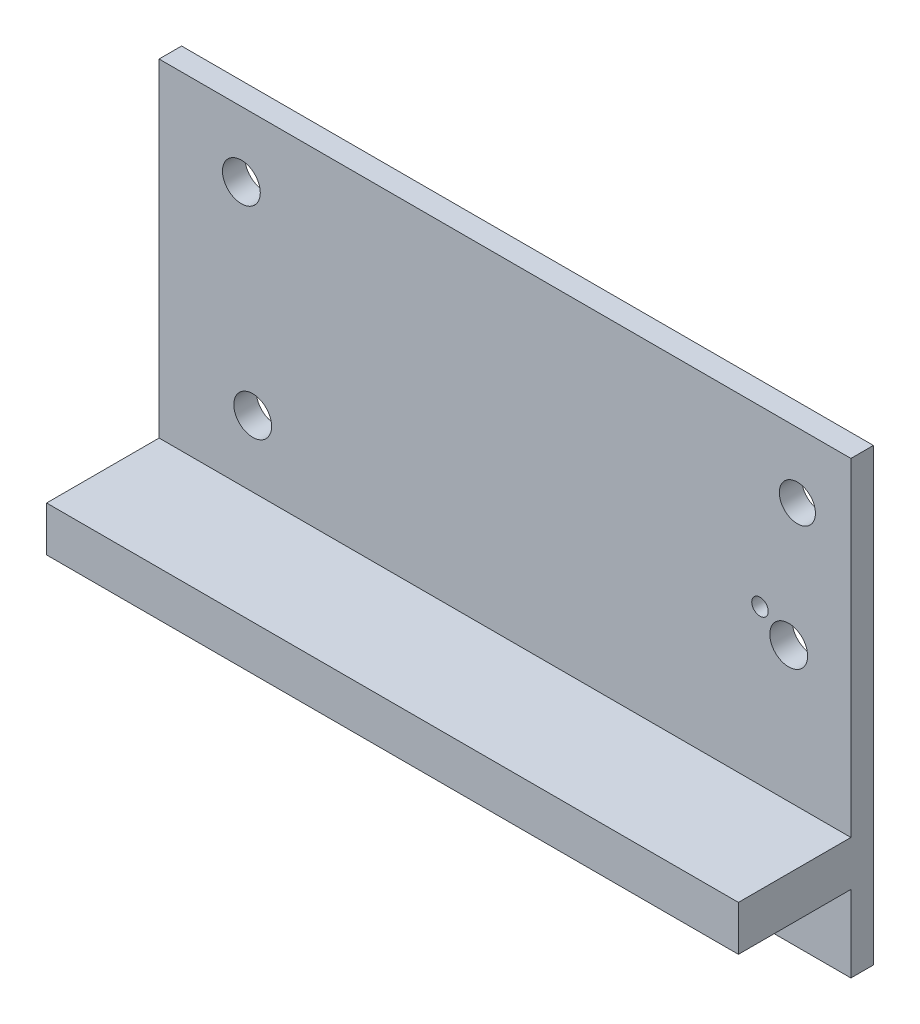
from build123d import *

# Parameters (mm, degrees)
ESQUISSE14_W       = 61.498402753
ESQUISSE14_H       = 40
ESQUISSE14_R       = 1.605618906
ESQUISSE14_R_2     = 1.680447067
ESQUISSE14_R_3     = 0.733091197
BOSS_EXTRU_1_DEPTH = 2
ESQUISSE15_W       = 61.498402753
ESQUISSE15_H       = 4
BOSS_EXTRU_2_DEPTH = 10


with BuildPart() as part:
    # Esquisse14 → Boss.-Extru.1 (new body)
    with BuildSketch(Plane.XY):
        with Locations((52.452549346, -48.865029397)):
            Rectangle(ESQUISSE14_W, ESQUISSE14_H)
        with Locations((78.443148937, -34.669848165)):
            Circle(ESQUISSE14_R, mode=Mode.SUBTRACT)
        with Locations((77.672120282, -46.000448366)):
            Circle(ESQUISSE14_R_2, mode=Mode.SUBTRACT)
        with Locations((29.018235202, -34.669848165)):
            Circle(ESQUISSE14_R_2, mode=Mode.SUBTRACT)
        with Locations((30.026503442, -52.148907634)):
            Circle(ESQUISSE14_R_2, mode=Mode.SUBTRACT)
        with Locations((75.118944162, -44.320001299)):
            Circle(ESQUISSE14_R_3, mode=Mode.SUBTRACT)
    extrude(amount=-BOSS_EXTRU_1_DEPTH)

    # Esquisse15 → Boss.-Extru.2 (add)
    with BuildSketch(Plane.XY):
        with Locations((52.452549346, -60.045029397)):
            Rectangle(ESQUISSE15_W, ESQUISSE15_H)
    extrude(amount=BOSS_EXTRU_2_DEPTH)


solid = part.part
